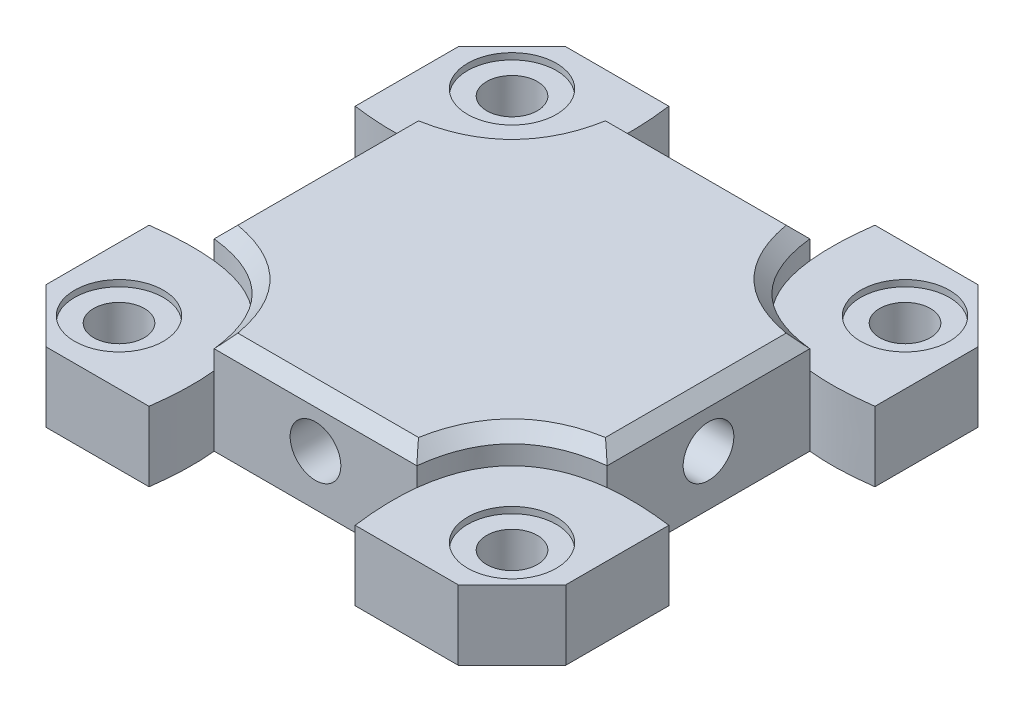
from build123d import *

# Parameters (mm, degrees)
SKETCH2_W            = 41
SKETCH2_H            = 41
BOSS_EXTRUDE1_DEPTH  = 2
SKETCH3_R            = 2
CUT_EXTRUDE1_DEPTH   = 30.060282173
SKETCH4_R            = 7.5
CUT_EXTRUDE2_DEPTH   = 30.060282173
SKETCH5_W            = 25
SKETCH5_H            = 25
CUT_EXTRUDE3_DEPTH   = 1
CUT_EXTRUDE4_DEPTH   = 30.060282173
SKETCH7_R            = 2
CUT_EXTRUDE5_DEPTH   = 30.060282173
SKETCH8_W            = 25
SKETCH8_H            = 8
SKETCH8_H_2          = 7.957817611
BOSS_EXTRUDE2_DEPTH  = 3.5
SKETCH9_R            = 2
CUT_EXTRUDE6_DEPTH   = 30.508473359
SKETCH10_R           = 2
BOSS_EXTRUDE3_DEPTH  = 3.5
SKETCH11_R           = 3.5
CUT_EXTRUDE7_DEPTH   = 3.5
SKETCH12_W           = 8
SKETCH12_H           = 2
BOSS_EXTRUDE4_DEPTH  = 3.5
SKETCH13_R           = 3.5
CUT_EXTRUDE8_DEPTH   = 3.5
SKETCH14_R           = 3.5
SKETCH14_R_2         = 2
BOSS_EXTRUDE5_DEPTH  = 3
SKETCH15_W           = 16
SKETCH15_H           = 8.042182389
SKETCH15_R           = 2
SKETCH15_H_2         = 8
BOSS_EXTRUDE6_DEPTH  = 4
CHAMFER1_SIZE        = 0.5
CHAMFER2_SIZE        = 0.5
SKETCH16_W           = 8
SKETCH16_H           = 25
CUT_EXTRUDE9_DEPTH   = 3.5
SKETCH17_W           = 30.600162952
SKETCH17_H           = 49.890212438
CUT_EXTRUDE10_DEPTH  = 4
SKETCH18_R           = 14.015002482
BOSS_EXTRUDE7_DEPTH  = 1
SKETCH19_R           = 2
BOSS_EXTRUDE8_DEPTH  = 5.5
SKETCH21_W           = 41
SKETCH21_H           = 25
BOSS_EXTRUDE9_DEPTH  = 4.5
BOSS_EXTRUDE10_DEPTH = 2.5
CUT_EXTRUDE12_DEPTH  = 31.07490662
SKETCH25_R           = 2
CUT_EXTRUDE13_DEPTH  = 5
SKETCH26_R           = 2
CUT_EXTRUDE14_DEPTH  = 5
CHAMFER3_SIZE        = 1


with BuildPart() as part:
    # Sketch2 → Boss-Extrude1 (new body)
    with BuildSketch(Plane(origin=(0, 0, 0), x_dir=(1, 0, 0), z_dir=(0, 1, 0))):
        Rectangle(SKETCH2_W, SKETCH2_H)
    extrude(amount=BOSS_EXTRUDE1_DEPTH)

    # Sketch3 → Cut-Extrude1 (cut, through all)
    with BuildSketch(Plane.XZ):
        with Locations(Location((-7.943181907, 8.037155044, 0), (0, 0, 270))):
            Circle(SKETCH3_R)
        with Locations(Location((8.037155044, 7.943181907, 0), (0, 0, 270))):
            Circle(SKETCH3_R)
        with Locations(Location((7.943181907, -8.037155044, 0), (0, 0, 270))):
            Circle(SKETCH3_R)
        with Locations(Location((-8.037155044, -7.943181907, 0), (0, 0, 270))):
            Circle(SKETCH3_R)
    extrude(amount=-CUT_EXTRUDE1_DEPTH, mode=Mode.SUBTRACT)

    # Sketch4 → Cut-Extrude2 (cut, through all)
    with BuildSketch(Plane(origin=(0, 2, 0), x_dir=(1, 0, 0), z_dir=(0, 1, 0))):
        with Locations(Location((0, 0, 0), (0, 0, 270))):
            Circle(SKETCH4_R)
    extrude(amount=-CUT_EXTRUDE2_DEPTH, mode=Mode.SUBTRACT)

    # Sketch5 → Cut-Extrude3 (cut)
    with BuildSketch(Plane.XZ):
        Rectangle(SKETCH5_W, SKETCH5_H)
    extrude(amount=-CUT_EXTRUDE3_DEPTH, mode=Mode.SUBTRACT)

    # Sketch6 → Cut-Extrude4 (cut, through all)
    with BuildSketch(Plane(origin=(0, 2, 0), x_dir=(1, 0, 0), z_dir=(0, 1, 0))):
        Polygon((-20.5, 16.257359313), (-16.257359313, 20.5), (-20.5, 20.5), align=None)
        Polygon((16.257359313, 20.5), (20.5, 16.257359313), (20.5, 20.5), align=None)
        Polygon((20.5, -16.257359313), (16.257359313, -20.5), (20.5, -20.5), align=None)
        Polygon((-16.257359313, -20.5), (-20.5, -16.257359313), (-20.5, -20.5), align=None)
    extrude(amount=-CUT_EXTRUDE4_DEPTH, mode=Mode.SUBTRACT)

    # Sketch7 → Cut-Extrude5 (cut, through all)
    with BuildSketch(Plane.XZ):
        with Locations(Location((-15.5, 15.5, 0), (0, 0, 270))):
            Circle(SKETCH7_R)
        with Locations(Location((15.5, 15.5, 0), (0, 0, 270))):
            Circle(SKETCH7_R)
        with Locations(Location((15.5, -15.5, 0), (0, 0, 270))):
            Circle(SKETCH7_R)
        with Locations(Location((-15.5, -15.5, 0), (0, 0, 270))):
            Circle(SKETCH7_R)
    extrude(amount=-CUT_EXTRUDE5_DEPTH, mode=Mode.SUBTRACT)

    # Sketch8 → Boss-Extrude2 (add)
    with BuildSketch(Plane.XZ):
        with Locations((0, 16.5)):
            Rectangle(SKETCH8_W, SKETCH8_H)
        with Locations((0, -16.478908806)):
            Rectangle(SKETCH8_W, SKETCH8_H_2)
    extrude(amount=BOSS_EXTRUDE2_DEPTH)

    # Sketch9 → Cut-Extrude6 (cut, through all)
    with BuildSketch(Plane.XZ.offset(3.5)):
        with Locations(Location((0, 16.5, 0), (0, 0, 270))):
            Circle(SKETCH9_R)
        with Locations(Location((0, -16.478908806, 0), (0, 0, 270))):
            Circle(SKETCH9_R)
    extrude(amount=-CUT_EXTRUDE6_DEPTH, mode=Mode.SUBTRACT)

    # Sketch10 → Boss-Extrude3 (add)
    with BuildSketch(Plane.XZ):
        Polygon((-20.5, 16.257359313), (-20.5, 12.5), (-12.5, 12.5), (-12.5, 20.5), (-16.257359313, 20.5), align=None)
        with Locations(Location((-15.5, 15.5, 0), (0, 0, 270))):
            Circle(SKETCH10_R, mode=Mode.SUBTRACT)
        Polygon((12.5, 12.5), (20.5, 12.5), (20.5, 16.257359313), (16.257359313, 20.5), (12.5, 20.5), align=None)
        with Locations(Location((15.5, 15.5, 0), (0, 0, 270))):
            Circle(SKETCH10_R, mode=Mode.SUBTRACT)
        Polygon((-20.5, -12.5), (-20.5, -16.257359313), (-16.257359313, -20.5), (16.257359313, -20.5), (20.5, -16.257359313), (20.5, -12.5), (12.5, -12.5), (12.5, -20.457817611), (-12.5, -20.457817611), (-12.5, -12.5), align=None)
        with Locations(Location((-15.5, -15.5, 0), (0, 0, 270))):
            Circle(SKETCH10_R, mode=Mode.SUBTRACT)
        with Locations(Location((15.5, -15.5, 0), (0, 0, 270))):
            Circle(SKETCH10_R, mode=Mode.SUBTRACT)
    extrude(amount=BOSS_EXTRUDE3_DEPTH)

    # Sketch11 → Cut-Extrude7 (cut)
    with BuildSketch(Plane(origin=(0, 2, 0), x_dir=(1, 0, 0), z_dir=(0, 1, 0))):
        with Locations(Location((-15.5, 15.5, 0), (0, 0, 270))):
            Circle(SKETCH11_R)
        with Locations(Location((15.5, 15.5, 0), (0, 0, 270))):
            Circle(SKETCH11_R)
        with Locations(Location((15.5, -15.5, 0), (0, 0, 270))):
            Circle(SKETCH11_R)
        with Locations(Location((-15.5, -15.5, 0), (0, 0, 270))):
            Circle(SKETCH11_R)
    extrude(amount=-CUT_EXTRUDE7_DEPTH, mode=Mode.SUBTRACT)

    # Sketch12 → Boss-Extrude4 (add)
    with BuildSketch(Plane.XZ):
        with Locations((-16.5, -11.5)):
            Rectangle(SKETCH12_W, SKETCH12_H)
        with Locations((-16.5, 11.5)):
            Rectangle(SKETCH12_W, SKETCH12_H)
        with Locations((16.5, -11.5)):
            Rectangle(SKETCH12_W, SKETCH12_H)
        with Locations((16.5, 11.5)):
            Rectangle(SKETCH12_W, SKETCH12_H)
    extrude(amount=BOSS_EXTRUDE4_DEPTH)

    # Sketch13 → Cut-Extrude8 (cut)
    with BuildSketch(Plane(origin=(0, 2, 0), x_dir=(1, 0, 0), z_dir=(0, 1, 0))):
        with Locations(Location((-15.5, 15.5, 0), (0, 0, 270))):
            Circle(SKETCH13_R)
        with Locations(Location((15.5, 15.5, 0), (0, 0, 270))):
            Circle(SKETCH13_R)
        with Locations(Location((15.5, -15.5, 0), (0, 0, 270))):
            Circle(SKETCH13_R)
        with Locations(Location((-15.5, -15.5, 0), (0, 0, 270))):
            Circle(SKETCH13_R)
    extrude(amount=-CUT_EXTRUDE8_DEPTH, mode=Mode.SUBTRACT)

    # Sketch14 → Boss-Extrude5 (add)
    with BuildSketch(Plane(origin=(0, -1.5, 0), x_dir=(1, 0, 0), z_dir=(0, 1, 0))):
        with Locations(Location((-15.5, -15.5, 0), (0, 0, 270))):
            Circle(SKETCH14_R)
        with Locations(Location((-15.5, -15.5, 0), (0, 0, 90))):
            Circle(SKETCH14_R_2, mode=Mode.SUBTRACT)
        with Locations(Location((-15.5, 15.5, 0), (0, 0, 270))):
            Circle(SKETCH14_R)
        with Locations(Location((-15.5, 15.5, 0), (0, 0, 90))):
            Circle(SKETCH14_R_2, mode=Mode.SUBTRACT)
        with Locations(Location((15.5, 15.5, 0), (0, 0, 270))):
            Circle(SKETCH14_R)
        with Locations(Location((15.5, 15.5, 0), (0, 0, 90))):
            Circle(SKETCH14_R_2, mode=Mode.SUBTRACT)
        with Locations(Location((15.5, -15.5, 0), (0, 0, 270))):
            Circle(SKETCH14_R)
        with Locations(Location((15.5, -15.5, 0), (0, 0, 90))):
            Circle(SKETCH14_R_2, mode=Mode.SUBTRACT)
    extrude(amount=BOSS_EXTRUDE5_DEPTH)

    # Sketch15 → Boss-Extrude6 (add)
    with BuildSketch(Plane(origin=(0, 2, 0), x_dir=(1, 0, 0), z_dir=(0, 1, 0))):
        with Locations((0, 16.478908806)):
            Rectangle(SKETCH15_W, SKETCH15_H)
        with Locations(Location((0, 16.478908806, 0), (0, 0, 90))):
            Circle(SKETCH15_R, mode=Mode.SUBTRACT)
        with Locations((0, -16.5)):
            Rectangle(SKETCH15_W, SKETCH15_H_2)
        with Locations(Location((0, -16.478908806, 0), (0, 0, 90))):
            Circle(SKETCH15_R, mode=Mode.SUBTRACT)
    extrude(amount=BOSS_EXTRUDE6_DEPTH)

    # Chamfer1
    chamfer1_edges = [part.edges().sort_by_distance(p)[0] for p in [
        (0, 6, -14.478908806),
        (0, 6, 18.478908806),
    ]]
    chamfer(chamfer1_edges, length=CHAMFER1_SIZE)

    # Chamfer2
    chamfer2_edges = [part.edges().sort_by_distance(p)[0] for p in [
        (-8, 6, -16.478908806),
        (0, 6, -12.457817611),
        (8, 6, -16.478908806),
        (0, 6, -20.5),
        (-8, 6, 16.5),
        (0, 6, 20.5),
        (8, 6, 16.5),
        (0, 6, 12.5),
    ]]
    chamfer(chamfer2_edges, length=CHAMFER2_SIZE)

    # Sketch16 → Cut-Extrude9 (cut)
    with BuildSketch(Plane.XZ.offset(3.5)):
        with Locations((-16.5, 0)):
            Rectangle(SKETCH16_W, SKETCH16_H)
        with Locations((16.5, 0)):
            Rectangle(SKETCH16_W, SKETCH16_H)
    extrude(amount=-CUT_EXTRUDE9_DEPTH, mode=Mode.SUBTRACT)

    # Sketch17 → Cut-Extrude10 (cut)
    with BuildSketch(Plane(origin=(0, 6, 0), x_dir=(1, 0, 0), z_dir=(0, 1, 0))):
        Rectangle(SKETCH17_W, SKETCH17_H)
    extrude(amount=-CUT_EXTRUDE10_DEPTH, mode=Mode.SUBTRACT)

    # Sketch18 → Boss-Extrude7 (add)
    with BuildSketch(Plane(origin=(0, 2, 0), x_dir=(1, 0, 0), z_dir=(0, 1, 0))):
        Circle(SKETCH18_R)
    extrude(amount=-BOSS_EXTRUDE7_DEPTH)

    # Sketch19 → Boss-Extrude8 (add)
    with BuildSketch(Plane(origin=(0, 2, 0), x_dir=(1, 0, 0), z_dir=(0, 1, 0))):
        with Locations((0, 16.478908806)):
            Circle(SKETCH19_R)
        with Locations((0, -16.5)):
            Circle(SKETCH19_R)
    extrude(amount=-BOSS_EXTRUDE8_DEPTH)

    # Sketch21 → Boss-Extrude9 (add)
    with BuildSketch(Plane.XZ.offset(-1)):
        Rectangle(SKETCH21_W, SKETCH21_H)
    extrude(amount=BOSS_EXTRUDE9_DEPTH)

    # Sketch22 → Boss-Extrude10 (add)
    with BuildSketch(Plane(origin=(0, 2, 0), x_dir=(1, 0, 0), z_dir=(0, 1, 0))):
        with BuildLine():
            Line((-20.5, 8.128679656), (-20.5, -8.128679656))
            add(Edge.make_bspline(
                [(-20.5, -8.128679656), (-6.185660172, -6.185660172), (-8.128679656, -20.5)],
                knots=[0, 0, 0, 1, 1, 1], degree=2))
            Line((-8.128679656, -20.5), (8.128679656, -20.5))
            add(Edge.make_bspline(
                [(8.128679656, -20.5), (6.185660172, -6.185660172), (20.5, -8.128679656)],
                knots=[0, 0, 0, 1, 1, 1], degree=2))
            Line((20.5, -8.128679656), (20.5, 8.128679656))
            add(Edge.make_bspline(
                [(8.128679656, 20.5), (6.185660172, 6.185660172), (20.5, 8.128679656)],
                knots=[0, 0, 0, 1, 1, 1], degree=2))
            Line((8.128679656, 20.5), (-8.128679656, 20.5))
            add(Edge.make_bspline(
                [(-8.128679656, 20.5), (-6.185660172, 6.185660172), (-20.5, 8.128679656)],
                knots=[0, 0, 0, 1, 1, 1], degree=2))
        make_face()
    extrude(amount=BOSS_EXTRUDE10_DEPTH)

    # Sketch24 → Cut-Extrude12 (cut, through all)
    with BuildSketch(Plane(origin=(0, 4.5, 0), x_dir=(1, 0, 0), z_dir=(0, 1, 0))):
        with BuildLine():
            Line((-20.500000014, 8.128679658), (-20.5, -8.128679656))
            add(Edge.make_bspline(
                [(-20.5, -8.128679656), (-17.685817605, -7.746684308), (-15.5, -7.99305375)],
                knots=[0, 0, 0, 1, 1, 1], degree=2))
            Line((-15.5, -7.99305375), (-15.5, 7.99305375))
            add(Edge.make_bspline(
                [(-15.5, 7.99305375), (-17.685817611, 7.746684308), (-20.500000014, 8.128679658)],
                knots=[0, 0, 0, 1, 1, 1], degree=2))
        make_face()
        with BuildLine():
            Line((-8.128679658, -20.500000014), (8.128679656, -20.5))
            add(Edge.make_bspline(
                [(8.128679656, -20.5), (7.746684308, -17.685817605), (7.99305375, -15.5)],
                knots=[0, 0, 0, 1, 1, 1], degree=2))
            Line((7.99305375, -15.5), (-7.99305375, -15.5))
            add(Edge.make_bspline(
                [(-7.99305375, -15.5), (-7.746684308, -17.685817611), (-8.128679658, -20.500000014)],
                knots=[0, 0, 0, 1, 1, 1], degree=2))
        make_face()
        with BuildLine():
            Line((20.500000014, -8.128679658), (20.5, 8.128679656))
            add(Edge.make_bspline(
                [(20.5, 8.128679656), (17.685817605, 7.746684308), (15.5, 7.99305375)],
                knots=[0, 0, 0, 1, 1, 1], degree=2))
            Line((15.5, 7.99305375), (15.5, -7.99305375))
            add(Edge.make_bspline(
                [(15.5, -7.99305375), (17.685817611, -7.746684308), (20.500000014, -8.128679658)],
                knots=[0, 0, 0, 1, 1, 1], degree=2))
        make_face()
        with BuildLine():
            Line((8.128679658, 20.500000014), (-8.128679653, 20.499999973))
            add(Edge.make_bspline(
                [(-8.128679653, 20.499999973), (-7.746684309, 17.685817595), (-7.99305375, 15.5)],
                knots=[0, 0, 0, 1, 1, 1], degree=2))
            Line((-7.99305375, 15.5), (7.99305375, 15.5))
            add(Edge.make_bspline(
                [(7.99305375, 15.5), (7.746684308, 17.685817611), (8.128679658, 20.500000014)],
                knots=[0, 0, 0, 1, 1, 1], degree=2))
        make_face()
    extrude(amount=-CUT_EXTRUDE12_DEPTH, mode=Mode.SUBTRACT)

    # Sketch25 → Cut-Extrude13 (cut)
    with BuildSketch(Plane.XY.offset(15.5)):
        with Locations((0, 0.5)):
            Circle(SKETCH25_R)
    cut_extrude13 = extrude(amount=-CUT_EXTRUDE13_DEPTH, mode=Mode.SUBTRACT)

    # Mirror1: Cut-Extrude13 across plane
    add(cut_extrude13.mirror(Plane.XY), mode=Mode.SUBTRACT)

    # Sketch26 → Cut-Extrude14 (cut)
    with BuildSketch(Plane(origin=(15.5, 0, 0), x_dir=(1.639002076151918e-12, 0, -1.0), z_dir=(1.0, 0, 1.639002076151918e-12))):
        with Locations((0, 0.5)):
            Circle(SKETCH26_R)
    cut_extrude14 = extrude(amount=-CUT_EXTRUDE14_DEPTH, mode=Mode.SUBTRACT)

    # Mirror2: Cut-Extrude14 across plane
    add(cut_extrude14.mirror(Plane(origin=(0, 0, 0), x_dir=(0, 0, 1), z_dir=(1, 0, 0))), mode=Mode.SUBTRACT)

    # Chamfer3
    chamfer3_edges = [part.edges().sort_by_distance(p)[0] for p in [
        (-10.249994711, 4.5, -10.250005289),
        (-10.250005289, 4.5, 10.249994711),
        (10.249994711, 4.5, 10.250005289),
        (10.249994711, 4.5, -10.250005289),
        (0, 4.5, -15.5),
        (-15.5, 4.5, 0),
        (15.5, 4.5, 0),
        (0, 4.5, 15.5),
    ]]
    chamfer(chamfer3_edges, length=CHAMFER3_SIZE)


solid = part.part
